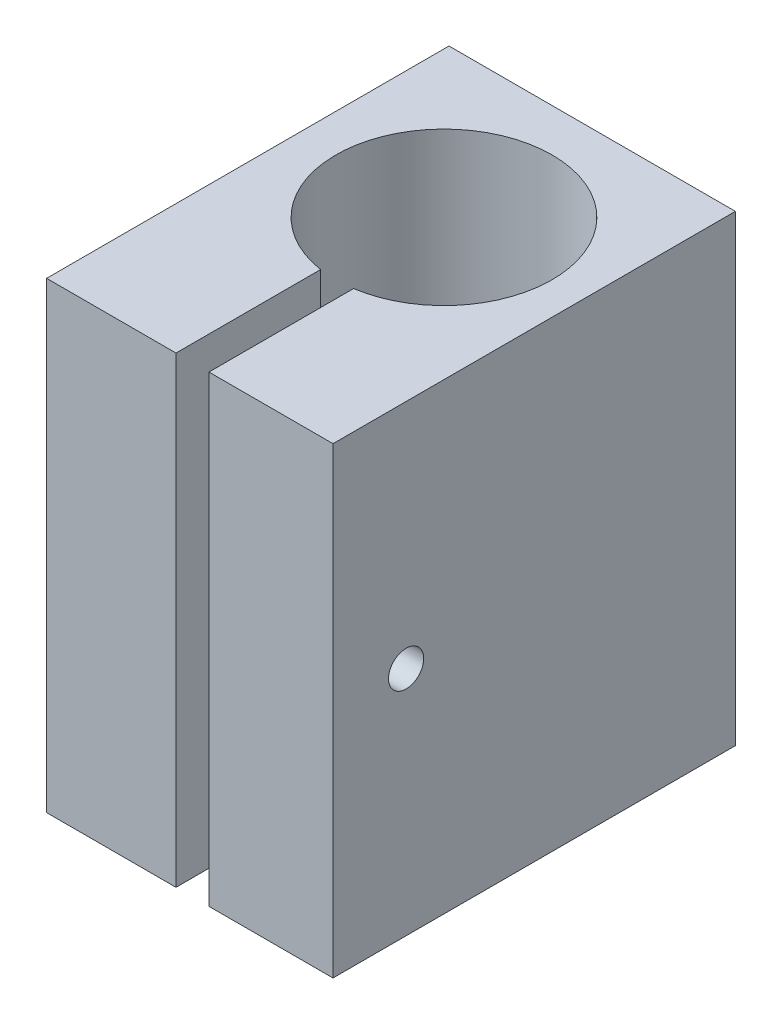
from build123d import *

# Parameters (mm, degrees)
EXTRUDE_1_DEPTH     = 46
CUT_EXTRUDE_1_DEPTH = 3
SKETCH_3_R          = 1.75
CUT_EXTRUDE_2_DEPTH = 26.47


with BuildPart() as part:
    # Эскиз1 → Бобышка-Вытянуть1 (new body)
    with BuildSketch(Plane(origin=(0, 0, 0), x_dir=(1, 0, 0), z_dir=(0, 1, 0))):
        with BuildLine():
            Line((-14.235, 20), (14.235, 20))
            Line((14.235, 20), (14.235, -20))
            Line((14.235, -20), (1.903095238, -20))
            Line((1.903095238, -20), (1.903095238, -5.624459703))
            ThreePointArc((1.903095238, -5.624459703), (0.265, 15.75), (-1.373095238, -5.624459703))
            Line((-1.373095238, -5.624459703), (-1.373095238, -20))
            Line((-1.373095238, -20), (-14.235, -20))
            Line((-14.235, -20), (-14.235, 20))
        make_face()
    extrude(amount=EXTRUDE_1_DEPTH)

    # Эскиз2 → Вырез-Вытянуть1 (cut)
    with BuildSketch(Plane.ZY.offset(14.235)):
        Polygon((12.733013434, 19.75), (15.547595996, 21.375), (15.547595996, 24.625), (12.733013434, 26.25), (9.918430872, 24.625), (9.918430872, 21.375), align=None)
    extrude(amount=-CUT_EXTRUDE_1_DEPTH, mode=Mode.SUBTRACT)

    # Эскиз3 → Вырез-Вытянуть2 (cut, through all)
    with BuildSketch(Plane.ZY.offset(11.235)):
        with Locations((12.733013434, 23)):
            Circle(SKETCH_3_R)
    extrude(amount=-CUT_EXTRUDE_2_DEPTH, mode=Mode.SUBTRACT)


solid = part.part
